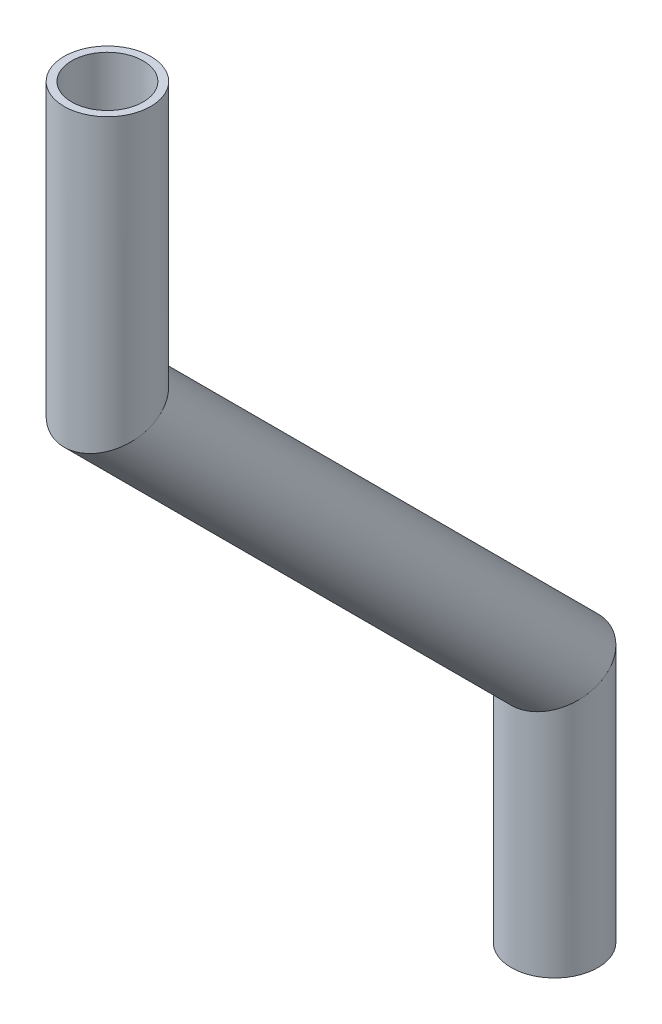
from build123d import *

# Parameters (mm, degrees)
SKETCH11_ON_SEGMENT_1_R        = 3.175
SKETCH11_ON_SEGMENT_1_R_2      = 2.6162
PIPE_0_5_SCH_40_1_DEPTH        = 20.815092915
SKETCH11_R                     = 3.175
SKETCH11_R_2                   = 2.6162
PIPE_0_5_SCH_40_1_2_DEPTH      = 49.184193112
PIPE_0_5_SCH_40_1_2_DEPTH_BACK = 2.859871939
SKETCH11_ON_SEGMENT_3_R        = 3.175
SKETCH11_ON_SEGMENT_3_R_2      = 2.6162
PIPE_0_5_SCH_40_1_3_DEPTH      = 23.163130032


with BuildPart() as part:
    # Sketch11 on segment 1 (carried to segment 1) → Pipe 0.5 SCH 40(1) (new body)
    with BuildSketch(Plane(origin=(0, 1553.903542435, 599.141033205), x_dir=(0, 0, 1), z_dir=(0, 1, 0))):
        Circle(SKETCH11_ON_SEGMENT_1_R)
        Circle(SKETCH11_ON_SEGMENT_1_R_2, mode=Mode.SUBTRACT)
    extrude(amount=PIPE_0_5_SCH_40_1_DEPTH)

    # Pipe 0.5 SCH 40(1) mitre 1
    split(bisect_by=Plane(origin=(0, 1571.858763411, 599.141033205), x_dir=(1, 0, 0), z_dir=(0, -0.923879533, -0.382683432)), keep=Keep.TOP)


with BuildPart() as body_2:
    # Sketch11 → Pipe 0.5 SCH 40_1 2 (new, two sides)
    with BuildSketch(Plane(origin=(0, 1571.858763411, 599.141033205), x_dir=(0, -0.7071067811865476, 0.7071067811865476), z_dir=(0, 0.7071067811865476, 0.7071067811865476))) as pipe_0_5_sch_40_1_2_sk:
        Circle(SKETCH11_R)
        Circle(SKETCH11_R_2, mode=Mode.SUBTRACT)
    extrude(amount=PIPE_0_5_SCH_40_1_2_DEPTH)
    extrude(pipe_0_5_sch_40_1_2_sk.sketch, amount=-PIPE_0_5_SCH_40_1_2_DEPTH_BACK)

    # Pipe 0.5 SCH 40_1 2 mitre 1
    split(bisect_by=Plane(origin=(0, 1571.858763411, 599.141033205), x_dir=(-1, 0, 0), z_dir=(0, 0.923879533, 0.382683432)), keep=Keep.TOP)

    # Pipe 0.5 SCH 40_1 2 mitre 2
    split(bisect_by=Plane(origin=(0, 1604.615005046, 631.89727484), x_dir=(1, 0, 0), z_dir=(0, -0.923879533, -0.382683432)), keep=Keep.TOP)


with BuildPart() as body_3:
    # Sketch11 on segment 3 (carried to segment 3) → Pipe 0.5 SCH 40_1 3 (new body)
    with BuildSketch(Plane(origin=(0, 1601.755133106, 631.89727484), x_dir=(0, 0, 1), z_dir=(0, 1, 0))):
        Circle(SKETCH11_ON_SEGMENT_3_R)
        Circle(SKETCH11_ON_SEGMENT_3_R_2, mode=Mode.SUBTRACT)
    extrude(amount=PIPE_0_5_SCH_40_1_3_DEPTH)

    # Pipe 0.5 SCH 40_1 3 mitre 1
    split(bisect_by=Plane(origin=(0, 1604.615005046, 631.89727484), x_dir=(-1, 0, 0), z_dir=(0, 0.923879533, 0.382683432)), keep=Keep.TOP)


solid = Compound([part.part, body_2.part, body_3.part])
